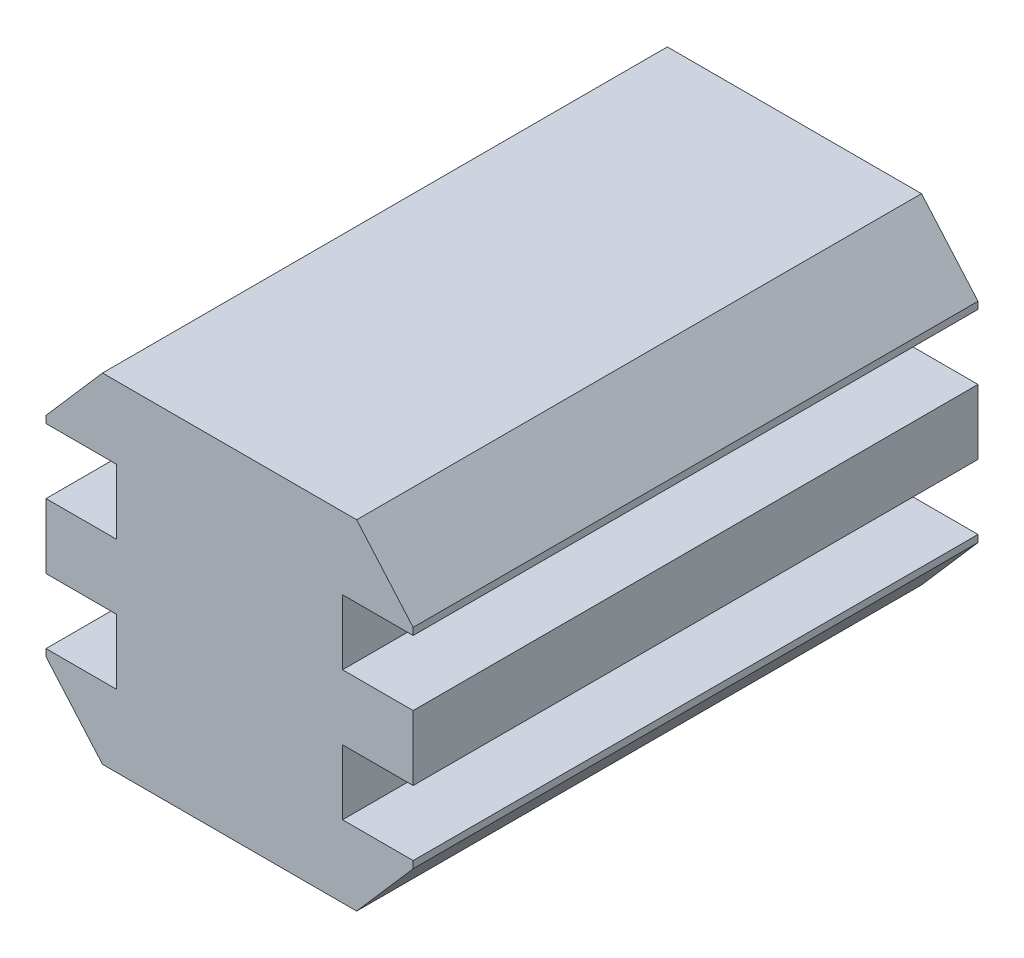
from build123d import *

# Parameters (mm, degrees)
RESSALTO_EXTRUS_O1_DEPTH = 20


with BuildPart() as part:
    # Esboço1 → Ressalto-extrusão1 (new body)
    with BuildSketch(Plane.XY):
        Polygon((-4.5, -6), (4.5, -6), (6.5, -3.7), (6.5, -3.45), (4, -3.45), (4, -1.15), (6.5, -1.15), (6.5, 1.15), (4, 1.15), (4, 3.45), (6.5, 3.45), (6.5, 3.7), (4.5, 6), (-4.5, 6), (-6.5, 3.7), (-6.5, 3.45), (-4, 3.45), (-4, 1.15), (-6.5, 1.15), (-6.5, -1.15), (-4, -1.15), (-4, -3.45), (-6.5, -3.45), (-6.5, -3.7), align=None)
    extrude(amount=RESSALTO_EXTRUS_O1_DEPTH)


solid = part.part
